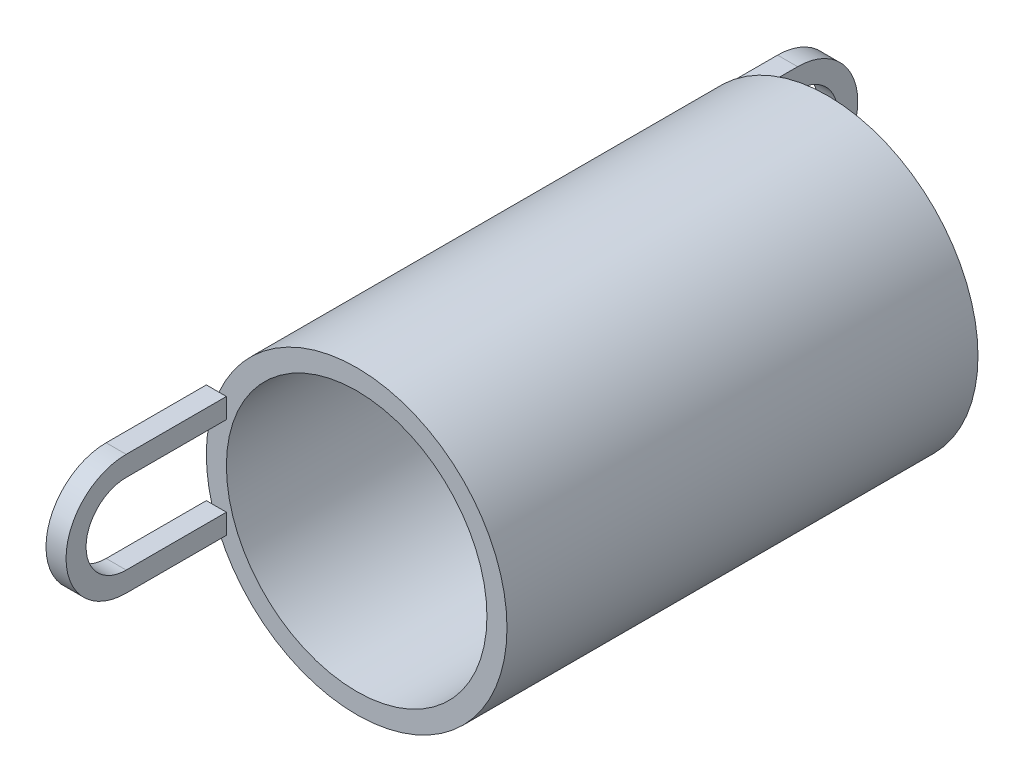
from build123d import *

# Parameters (mm, degrees)
ESBO_O2_R                = 7.5
ESBO_O2_R_2              = 6.5
RESSALTO_EXTRUS_O1_DEPTH = 23.5
RESSALTO_EXTRUS_O2_DEPTH = 1


with BuildPart() as part:
    # Esboço2 → Ressalto-extrusão1 (new body)
    with BuildSketch(Plane.XY):
        Circle(ESBO_O2_R)
        Circle(ESBO_O2_R_2, mode=Mode.SUBTRACT)
    extrude(amount=RESSALTO_EXTRUS_O1_DEPTH)

    # Esboço3 → Ressalto-extrusão2 (add)
    with BuildSketch(Plane(origin=(-7.5, 0, 0), x_dir=(0, 0, -1), z_dir=(1, 0, 0))):
        with BuildLine():
            Line((5, 2), (0, 2))
            Line((0, 2), (0, 3))
            Line((0, 3), (5, 3))
            ThreePointArc((5, 3), (8, 0), (5, -3))
            Line((5, -3), (0, -3))
            Line((0, -3), (0, -2))
            Line((0, -2), (5, -2))
            ThreePointArc((5, -2), (7, 0), (5, 2))
        make_face()
        with BuildLine():
            Line((-28.5, 3), (-23.5, 3))
            Line((-23.5, 3), (-23.5, 2))
            Line((-23.5, 2), (-28.5, 2))
            ThreePointArc((-28.5, 2), (-30.5, 0), (-28.5, -2))
            Line((-28.5, -2), (-23.5, -2))
            Line((-23.5, -2), (-23.5, -3))
            Line((-23.5, -3), (-28.5, -3))
            ThreePointArc((-28.5, -3), (-31.5, 0), (-28.5, 3))
        make_face()
    extrude(amount=RESSALTO_EXTRUS_O2_DEPTH)


solid = part.part
